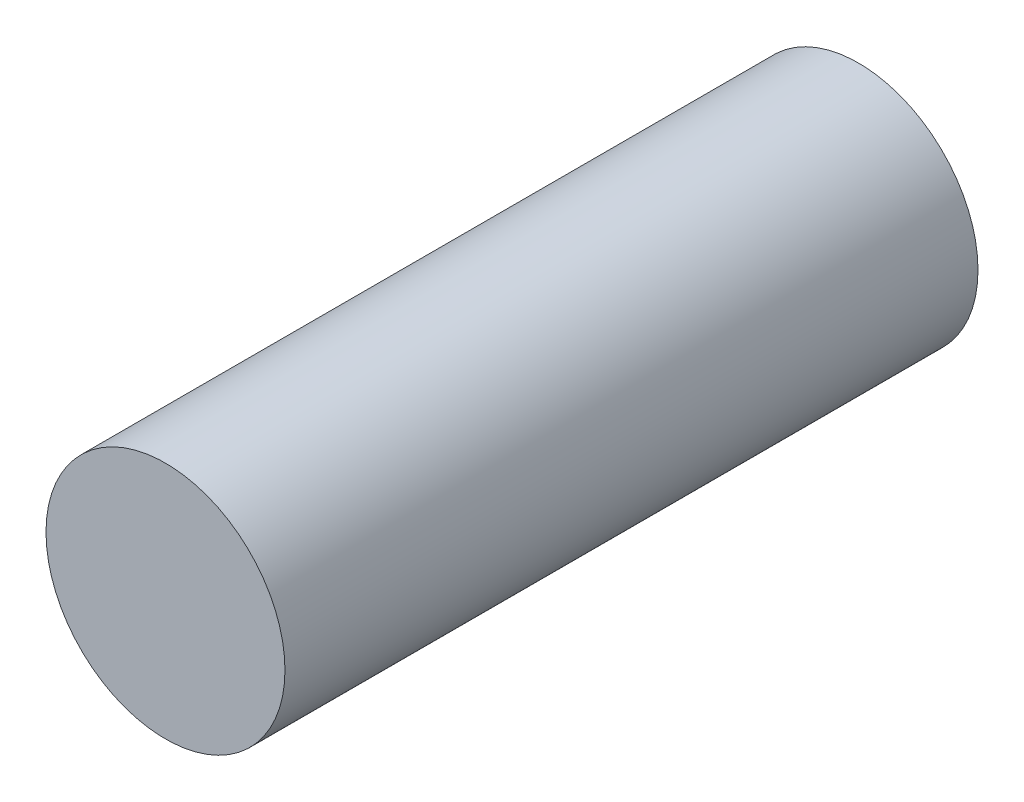
from build123d import *

# Parameters (mm, degrees)
SKETCH2_R           = 5
BOSS_EXTRUDE1_DEPTH = 29


with BuildPart() as part:
    # Sketch2 → Boss-Extrude1 (new body)
    with BuildSketch(Plane.XY):
        Circle(SKETCH2_R)
    extrude(amount=BOSS_EXTRUDE1_DEPTH)


solid = part.part
